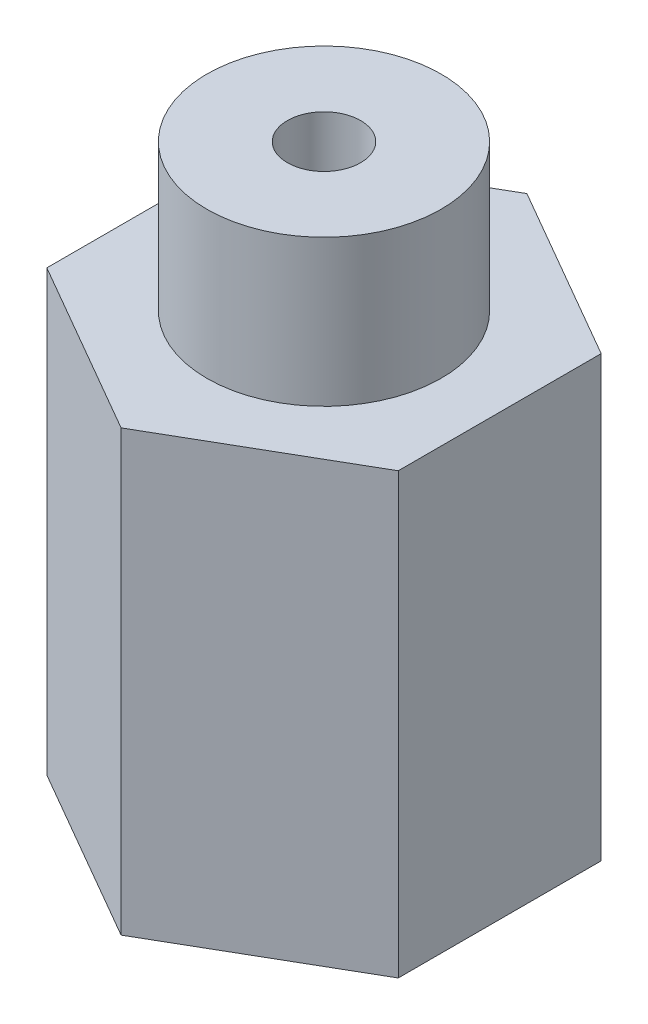
from build123d import *

# Parameters (mm, degrees)
EXTRUDE_1_DEPTH     = 40
SKETCH_3_R          = 2.5
CUT_EXTRUDE_2_DEPTH = 35
SKETCH_4_OUTSIDE_W  = 36.852
SKETCH_4_OUTSIDE_H  = 40.564
SKETCH_4_OUTSIDE_R  = 8
CUT_EXTRUDE_3_DEPTH = 10
SKETCH_5_R          = 5
CUT_EXTRUDE_4_DEPTH = 15


with BuildPart() as part:
    # Эскиз1 → Бобышка-Вытянуть1 (new body)
    with BuildSketch(Plane(origin=(0, 0, 0), x_dir=(1, 0, 0), z_dir=(0, 1, 0))):
        Polygon((0, 13.856406461), (-12, 6.92820323), (-12, -6.92820323), (0, -13.856406461), (12, -6.92820323), (12, 6.92820323), align=None)
    extrude(amount=EXTRUDE_1_DEPTH)

    # Эскиз3 → Вырез-Вытянуть2 (cut)
    with BuildSketch(Plane(origin=(0, 40, 0), x_dir=(1, 0, 0), z_dir=(0, 1, 0))):
        Circle(SKETCH_3_R)
    extrude(amount=-CUT_EXTRUDE_2_DEPTH, mode=Mode.SUBTRACT)

    # Эскиз4 outside → Вырез-Вытянуть3 (cut)
    with BuildSketch(Plane(origin=(0, 40, 0), x_dir=(1, 0, 0), z_dir=(0, 1, 0))):
        Rectangle(SKETCH_4_OUTSIDE_W, SKETCH_4_OUTSIDE_H)
        Circle(SKETCH_4_OUTSIDE_R, mode=Mode.SUBTRACT)
    extrude(amount=-CUT_EXTRUDE_3_DEPTH, mode=Mode.SUBTRACT)

    # Эскиз5 → Вырез-Вытянуть4 (cut)
    with BuildSketch(Plane(origin=(-6, 0, -10.392304845), x_dir=(-0.866025404, 0, 0.5), z_dir=(-0.5, 0, -0.866025404))):
        with Locations((0, 8)):
            Circle(SKETCH_5_R)
    extrude(amount=-CUT_EXTRUDE_4_DEPTH, mode=Mode.SUBTRACT)


solid = part.part
